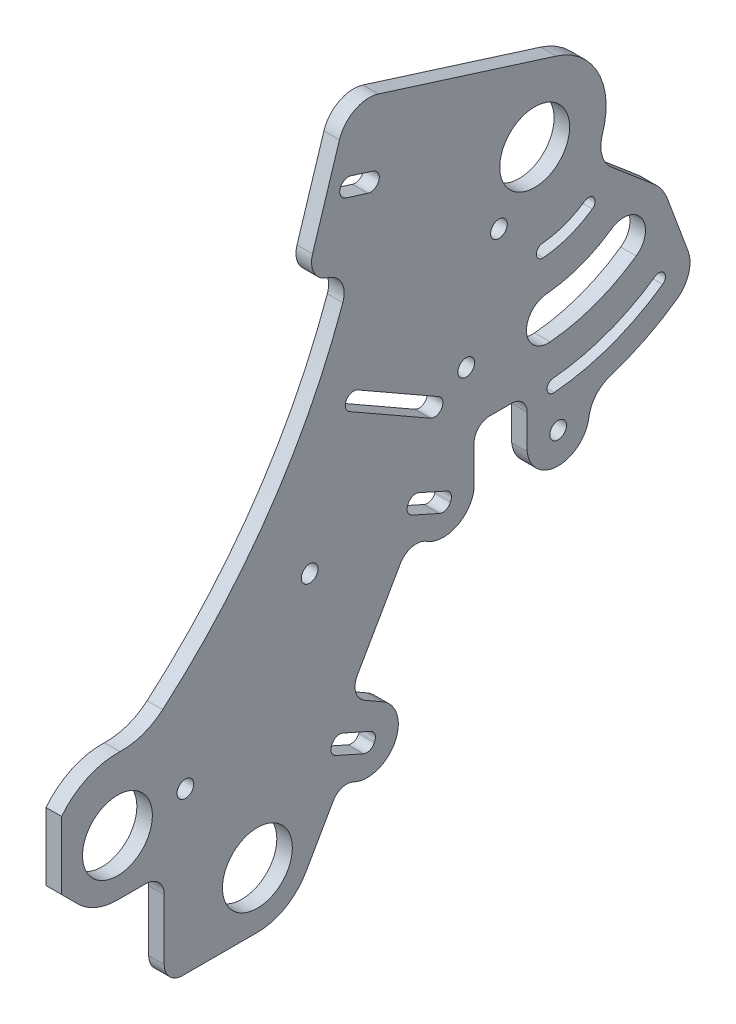
from build123d import *

# Parameters (mm, degrees)
BOSS_EXTRUDE1_DEPTH      = 3.175
BOSS_EXTRUDE1_DEPTH_BACK = 3.175
CUT_EXTRUDE1_DEPTH       = 307.149657193
CUT_EXTRUDE1_DEPTH_BACK  = 307.149657193
SKETCH1_R                = 14.2875
SKETCH1_R_2              = 3.429


with BuildPart() as part:
    # Sketch2 → Boss-Extrude1 (new, two sides: drawn at the far end of the back side and taken through both)
    with BuildSketch(Plane(origin=(0, 0, 0), x_dir=(0, 0, -1), z_dir=(1, 0, 0)).offset(-BOSS_EXTRUDE1_DEPTH_BACK)):
        with BuildLine():
            Line((-80.077770294, 30.595392043), (-80.077770294, 58.247946829))
            ThreePointArc((-80.077770294, 58.247946829), (-69.442421386, 66.593204099), (-56.188647306, 69.256179485))
            ThreePointArc((-56.188647306, 69.256179485), (-46.886526626, 70.672129884), (-38.738117997, 75.377212399))
            ThreePointArc((-38.738117997, 75.377212399), (5.090213079, 124.221234623), (34.945098816, 182.662204067))
            ThreePointArc((34.945098816, 182.662204067), (34.521299637, 189.805593755), (29.082706129, 194.456327313))
            Line((29.082706129, 194.456327313), (28.518829965, 194.634116785))
            ThreePointArc((28.518829965, 194.634116785), (23.157656737, 199.132675263), (22.547695998, 206.104558413))
            Line((22.547695998, 206.104558413), (33.54631132, 240.987709604))
            ThreePointArc((33.54631132, 240.987709604), (39.794309207, 248.433783532), (49.477480248, 249.280951225))
            Line((49.477480248, 249.280951225), (122.150711895, 226.367169303))
            ThreePointArc((122.150711895, 226.367169303), (139.389035794, 211.778713703), (141.073716499, 189.25884029))
            ThreePointArc((141.073716499, 189.25884029), (140.738510253, 182.410880382), (144.011829817, 176.386571529))
            Line((144.011829817, 176.386571529), (162.117995595, 161.015451766))
            ThreePointArc((162.117995595, 161.015451766), (165.394045644, 157.419573471), (167.652590835, 153.111230605))
            Line((167.652590835, 153.111230605), (176.079337299, 130.366637638))
            ThreePointArc((176.079337299, 130.366637638), (176.293542275, 122.170313769), (171.454830285, 115.551214511))
            ThreePointArc((171.454830285, 115.551214511), (158.356459409, 107.777887749), (144.240443192, 102.05687257))
            ThreePointArc((144.240443192, 102.05687257), (138.406050553, 98.151824286), (135.537778495, 91.743817189))
            ThreePointArc((135.537778495, 91.743817189), (122.733798507, 80.828311157), (110.332946369, 92.199724514))
            Line((110.332946369, 92.199724514), (110.287974786, 92.199724514))
            Line((110.287974786, 92.199724514), (110.287974786, 106.169724514))
            ThreePointArc((110.287974786, 106.169724514), (108.428102847, 110.659852575), (103.937974786, 112.519724514))
            Line((103.937974786, 112.519724514), (94.944067794, 112.519724514))
            ThreePointArc((94.944067794, 112.519724514), (90.453939734, 110.659852575), (88.594067794, 106.169724514))
            Line((88.594067794, 106.169724514), (88.594067794, 92.199724514))
            Line((88.594067794, 92.199724514), (88.594067794, 89.813112686))
            ThreePointArc((88.594067794, 89.813112686), (81.258269009, 80.137892516), (69.150347517, 81.044571224))
            ThreePointArc((69.150347517, 81.044571224), (63.214959672, 82.045828247), (58.4047538, 78.427366702))
            Line((58.4047538, 78.427366702), (40.912383352, 47.86429176))
            ThreePointArc((40.912383352, 47.86429176), (40.172936643, 42.0792631), (43.740701856, 37.465762324))
            Line((43.740701856, 37.465762324), (51.225250159, 33.182080404))
            ThreePointArc((51.225250159, 33.182080404), (56.134461156, 16.205485457), (39.322849283, 10.758024134))
            ThreePointArc((39.322849283, 10.758024134), (34.662129764, 11.127507824), (31.011761812, 8.206268627))
            Line((31.011761812, 8.206268627), (19.850909717, -11.336709549))
            ThreePointArc((19.850909717, -11.336709549), (11.476550434, -19.770391755), (0, -22.86))
            Line((0, -22.86), (-30.48, -22.86))
            ThreePointArc((-30.48, -22.86), (-35.868153673, -20.628153673), (-38.1, -15.24))
            Line((-38.1, -15.24), (-38.1, 9.584314079))
            ThreePointArc((-38.1, 9.584314079), (-40.331846327, 14.972467752), (-45.72, 17.204314079))
            Line((-45.72, 17.204314079), (-57.217770294, 17.204314079))
            ThreePointArc((-57.217770294, 17.204314079), (-65.965913557, 18.944427966), (-73.382231312, 23.899853061))
            Line((-73.382231312, 23.899853061), (-80.077770294, 30.595392043))
        make_face()
    extrude(amount=BOSS_EXTRUDE1_DEPTH + BOSS_EXTRUDE1_DEPTH_BACK)

    # Sketch1 → Cut-Extrude1 (cut, two sides: drawn at the far end of the back side and taken through both)
    with BuildSketch(Plane(origin=(0, 0, 0), x_dir=(0, 0, -1), z_dir=(1, 0, 0)).offset(-CUT_EXTRUDE1_DEPTH_BACK)):
        Circle(SKETCH1_R)
        with Locations((-57.217770294, 40.064314079)):
            Circle(SKETCH1_R)
        with Locations((113.367095492, 198.509097171)):
            Circle(SKETCH1_R)
        with Locations((-29.436520294, 42.726234079)):
            Circle(SKETCH1_R_2)
        with Locations((21.363479706, 93.526234079)):
            Circle(SKETCH1_R_2)
        with Locations((122.963479706, 93.526234079)):
            Circle(SKETCH1_R_2)
        with Locations((98.744155059, 176.904777846)):
            Circle(SKETCH1_R_2)
        with Locations((85.377782271, 134.512059385)):
            Circle(SKETCH1_R_2)
        with BuildLine():
            Line((30.555516965, 28.585224085), (30.360175827, 28.148630754))
            ThreePointArc((30.360175827, 28.148630754), (30.289083082, 25.61101973), (32.033174884, 23.766387604))
            Line((32.033174884, 23.766387604), (43.366777865, 18.695492686))
            ThreePointArc((43.366777865, 18.695492686), (45.904388889, 18.624399941), (47.749021015, 20.368491743))
            Line((47.749021015, 20.368491743), (47.944362153, 20.805085073))
            ThreePointArc((47.944362153, 20.805085073), (48.015454897, 23.342696098), (46.271363096, 25.187328223))
            Line((46.271363096, 25.187328223), (34.937760115, 30.258223141))
            ThreePointArc((34.937760115, 30.258223141), (32.40014909, 30.329315886), (30.555516965, 28.585224085))
        make_face()
        with BuildLine():
            Line((36.134107155, 219.131995286), (45.218261111, 216.267772546))
            ThreePointArc((45.218261111, 216.267772546), (49.67898841, 218.5898802), (47.356880757, 223.0506075))
            Line((47.356880757, 223.0506075), (38.272726801, 225.91483024))
            ThreePointArc((38.272726801, 225.91483024), (33.811999501, 223.592722586), (36.134107155, 219.131995286))
        make_face()
        with BuildLine():
            Line((61.67607301, 98.140604836), (61.480731873, 97.704011505))
            ThreePointArc((61.480731873, 97.704011505), (61.409639128, 95.166400481), (63.153730929, 93.321768355))
            Line((63.153730929, 93.321768355), (74.487333911, 88.250873437))
            ThreePointArc((74.487333911, 88.250873437), (77.024944935, 88.179780692), (78.86957706, 89.923872494))
            Line((78.86957706, 89.923872494), (79.064918198, 90.360465824))
            ThreePointArc((79.064918198, 90.360465824), (79.136010943, 92.898076849), (77.391919142, 94.742708974))
            Line((77.391919142, 94.742708974), (66.05831616, 99.813603892))
            ThreePointArc((66.05831616, 99.813603892), (63.520705136, 99.884696637), (61.67607301, 98.140604836))
        make_face()
        with BuildLine():
            Line((70.728471243, 123.847620068), (37.643621714, 142.742135984))
            ThreePointArc((37.643621714, 142.742135984), (36.366491689, 147.420278874), (41.044634579, 148.697408899))
            Line((41.044634579, 148.697408899), (74.129484108, 129.802892984))
            ThreePointArc((74.129484108, 129.802892984), (75.406614133, 125.124750094), (70.728471243, 123.847620068))
        make_face()
        with BuildLine():
            ThreePointArc((118.126670603, 144.106904708), (110.04531429, 134.475919289), (119.676299709, 126.394562976))
            ThreePointArc((119.676299709, 126.394562976), (138.125933667, 130.484748353), (154.888293719, 139.210680685))
            ThreePointArc((154.888293719, 139.210680685), (157.071460874, 151.592036878), (144.690104681, 153.775204033))
            ThreePointArc((144.690104681, 153.775204033), (132.044815519, 147.19248315), (118.126670603, 144.106904708))
        make_face()
        with BuildLine():
            ThreePointArc((116.483795739, 162.885050332), (114.059388845, 159.995754706), (116.948684471, 157.571347812))
            ThreePointArc((116.948684471, 157.571347812), (127.422113984, 159.893251235), (136.937717213, 164.846760742))
            ThreePointArc((136.937717213, 164.846760742), (137.59266736, 168.5611676), (133.878260502, 169.216117746))
            ThreePointArc((133.878260502, 169.216117746), (125.597778539, 164.905571674), (116.483795739, 162.885050332))
        make_face()
        with BuildLine():
            ThreePointArc((120.854285842, 112.930119872), (118.429878948, 110.040824247), (121.319174574, 107.616417353))
            ThreePointArc((121.319174574, 107.616417353), (144.572970647, 112.771659829), (165.700137899, 123.769766971))
            ThreePointArc((165.700137899, 123.769766971), (166.355088045, 127.484173829), (162.640681187, 128.139123976))
            ThreePointArc((162.640681187, 128.139123976), (142.748635202, 117.783980268), (120.854285842, 112.930119872))
        make_face()
    extrude(amount=CUT_EXTRUDE1_DEPTH + CUT_EXTRUDE1_DEPTH_BACK, mode=Mode.SUBTRACT)


solid = part.part
